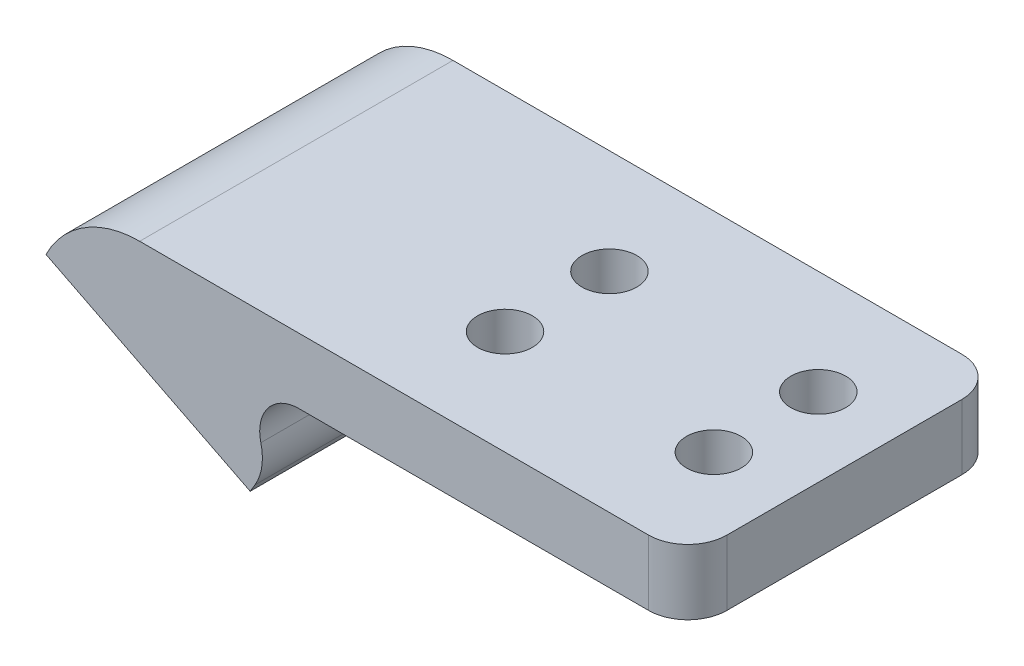
from build123d import *

# Parameters (mm, degrees)
ESQUISSE1_W             = 17
ESQUISSE1_H             = 5
BOSS_EXTRU_1_DEPTH      = 24
BOSS_EXTRU_2_DEPTH      = 24
CONG_1_R                = 4
CONG_2_R                = 8
CONG_3_R                = 3
ESQUISSE3_W             = 24
ESQUISSE3_H             = 5
BOSS_EXTRU_3_DEPTH      = 20
ESQUISSE4_R             = 2.1
ENL_V_MAT_EXTRU_1_DEPTH = 10
CONG_4_R                = 3
ESQUISSE5_R             = 2.25
ENL_V_MAT_EXTRU_2_DEPTH = 4


with BuildPart() as part:
    # Esquisse1 → Boss.-Extru.1 (new body)
    with BuildSketch(Plane.XY):
        with Locations((1.940369129, 2.5)):
            Rectangle(ESQUISSE1_W, ESQUISSE1_H)
    extrude(amount=BOSS_EXTRU_1_DEPTH)

    # Esquisse2 → Boss.-Extru.2 (add)
    with BuildSketch(Plane.XY.offset(24)):
        Polygon((-18.723069156, 0.535871193), (-3.080508445, -7.355303518), (-0.501566554, -3.056100904), (-16.471058056, 5), align=None)
        Polygon((-6.559630871, 0), (-6.559630871, 5), (-16.471058056, 5), align=None)
    extrude(amount=-BOSS_EXTRU_2_DEPTH)

    # Congé1
    cong_1_edges = [part.edges().sort_by_distance(p)[0] for p in [
        (-0.501566554, -3.056100904, 12),
    ]]
    fillet(cong_1_edges, radius=CONG_1_R)

    # Congé2
    cong_2_edges = [part.edges().sort_by_distance(p)[0] for p in [
        (-16.471058056, 5, 12),
    ]]
    fillet(cong_2_edges, radius=CONG_2_R)

    # Congé3
    cong_3_edges = [part.edges().sort_by_distance(p)[0] for p in [
        (-6.559630871, 0, 12),
    ]]
    fillet(cong_3_edges, radius=CONG_3_R)

    # Esquisse3 → Boss.-Extru.3 (add)
    with BuildSketch(Plane(origin=(10.440369129, 0, 0), x_dir=(0, 0, -1), z_dir=(1, 0, 0))):
        with Locations((-12, 2.5)):
            Rectangle(ESQUISSE3_W, ESQUISSE3_H)
    extrude(amount=BOSS_EXTRU_3_DEPTH)

    # Esquisse4 → Enlèv. mat.-Extru.1 (cut)
    with BuildSketch(Plane(origin=(0, 5, 0), x_dir=(1, 0, 0), z_dir=(0, 1, 0))):
        with Locations((8.440369129, -8)):
            Circle(ESQUISSE4_R)
        with Locations((24.440369129, -8)):
            Circle(ESQUISSE4_R)
        with Locations((8.440369129, -16)):
            Circle(ESQUISSE4_R)
        with Locations((24.440369129, -16)):
            Circle(ESQUISSE4_R)
    extrude(amount=-ENL_V_MAT_EXTRU_1_DEPTH, mode=Mode.SUBTRACT)

    # Congé4
    cong_4_edges = [part.edges().sort_by_distance(p)[0] for p in [
        (30.440369129, 2.5, 0),
        (30.440369129, 2.5, 24),
    ]]
    fillet(cong_4_edges, radius=CONG_4_R)

    # Esquisse5 → Enlèv. mat.-Extru.2 (cut)
    with BuildSketch(Plane(origin=(-3.582711985, -7.101957793, 0), x_dir=(0.892825761, -0.45040222, 0), z_dir=(-0.45040222, -0.892825761, 0))):
        with Locations((-12.147654158, 8.05)):
            Circle(ESQUISSE5_R)
        with Locations((-12.147654158, 15.95)):
            Circle(ESQUISSE5_R)
        with Locations((-4.247654158, 15.95)):
            Circle(ESQUISSE5_R)
        with Locations((-4.247654158, 8.05)):
            Circle(ESQUISSE5_R)
    extrude(amount=-ENL_V_MAT_EXTRU_2_DEPTH, mode=Mode.SUBTRACT)


solid = part.part
